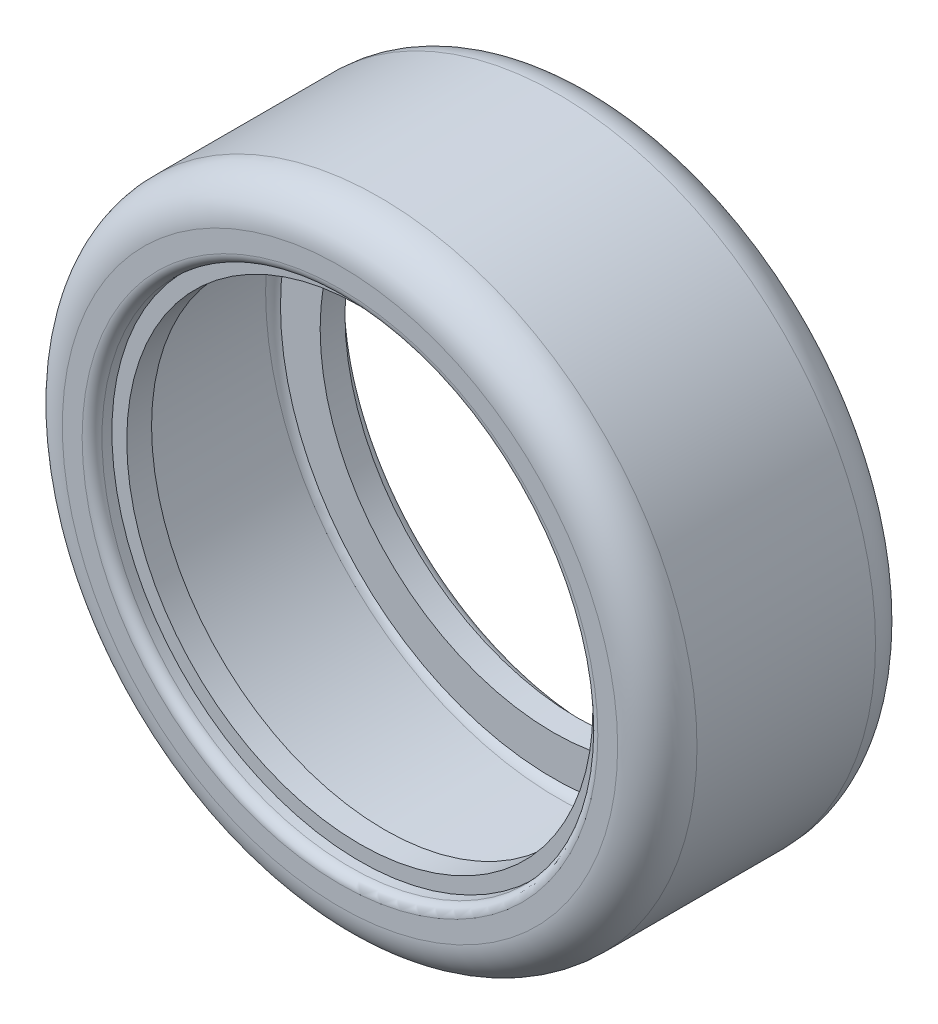
from build123d import *

# Parameters (mm, degrees)
ESQUISSE1_R             = 32
ESQUISSE1_R_2           = 23.5
BASE_EXTRUSION_DEPTH    = 13
CONG_1_R                = 4
ESQUISSE2_R             = 25
ENL_V_MAT_EXTRU_1_DEPTH = 2
CONG_2_R                = 1
COQUE1_T                = -2.5


with BuildPart() as part:
    # Esquisse1 → Base-Extrusion (new body, symmetric)
    with BuildSketch(Plane.XY):
        Circle(ESQUISSE1_R)
        Circle(ESQUISSE1_R_2, mode=Mode.SUBTRACT)
    extrude(amount=BASE_EXTRUSION_DEPTH, both=True)

    # Congé1
    cong_1_edges = [part.edges().sort_by_distance(p)[0] for p in [
        (-32, 0, -13),
        (-32, 0, 13),
    ]]
    fillet(cong_1_edges, radius=CONG_1_R)

    # Esquisse2 → Enlèv. mat.-Extru.1 (cut)
    with BuildSketch(Plane.XY.offset(13)):
        Circle(ESQUISSE2_R)
    enl_v_mat_extru_1 = extrude(amount=-ENL_V_MAT_EXTRU_1_DEPTH, mode=Mode.SUBTRACT)

    # Symétrie1: Enlèv. mat.-Extru.1 across plane
    add(enl_v_mat_extru_1.mirror(Plane.XY), mode=Mode.SUBTRACT)

    # Congé2
    cong_2_edges = [part.edges().sort_by_distance(p)[0] for p in [
        (-25, 0, -13),
        (-25, 0, 13),
    ]]
    fillet(cong_2_edges, radius=CONG_2_R)

    # Coque1
    coque1_openings = [part.faces().sort_by_distance(p)[0] for p in [
        (-23.5, 0, 0),
    ]]
    offset(amount=COQUE1_T, openings=coque1_openings, kind=Kind.INTERSECTION)


solid = part.part
